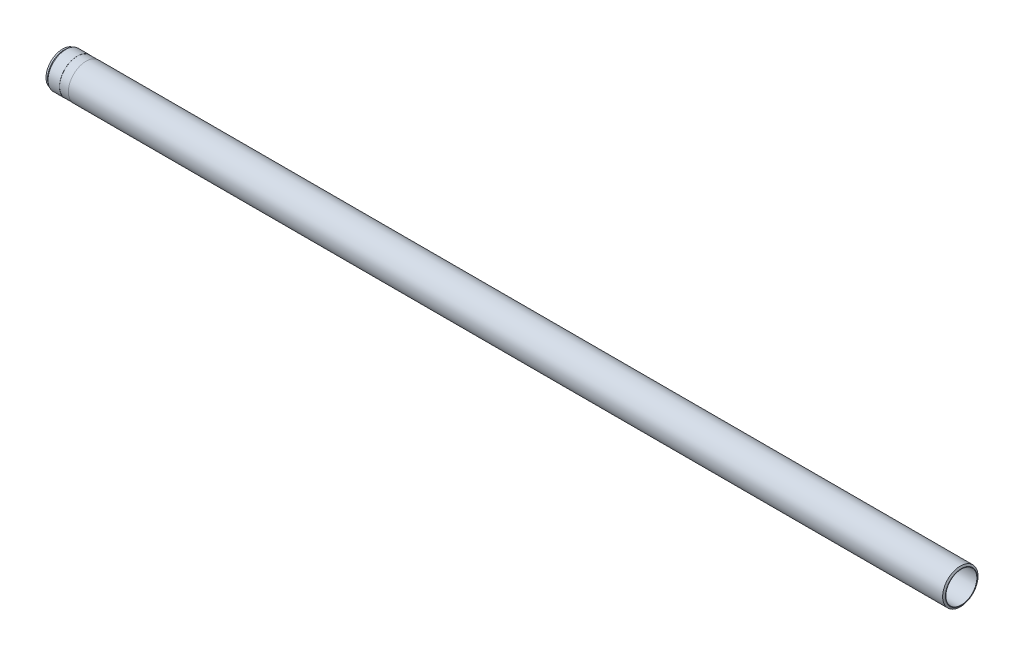
from build123d import *


with BuildPart() as part:
    # Sketch1 → Base-Revolve (revolve)
    with BuildSketch(Plane.XY):
        Polygon((0, 35), (0, 36), (-2.309401077, 40), (-1978, 40), (-1978, 39.75), (-1998, 39.75), (-1998, 40), (-2023.929629983, 40), (-2027.5, 37.5), (-2031, 37.5), (-2031, 35.727350269), (-2030, 35.15), (-2016, 35.15), (-2015.740192379, 35), align=None)
    revolve(axis=Axis((-122.784188742, 0, 0), (1, 0, 0)))


solid = part.part
